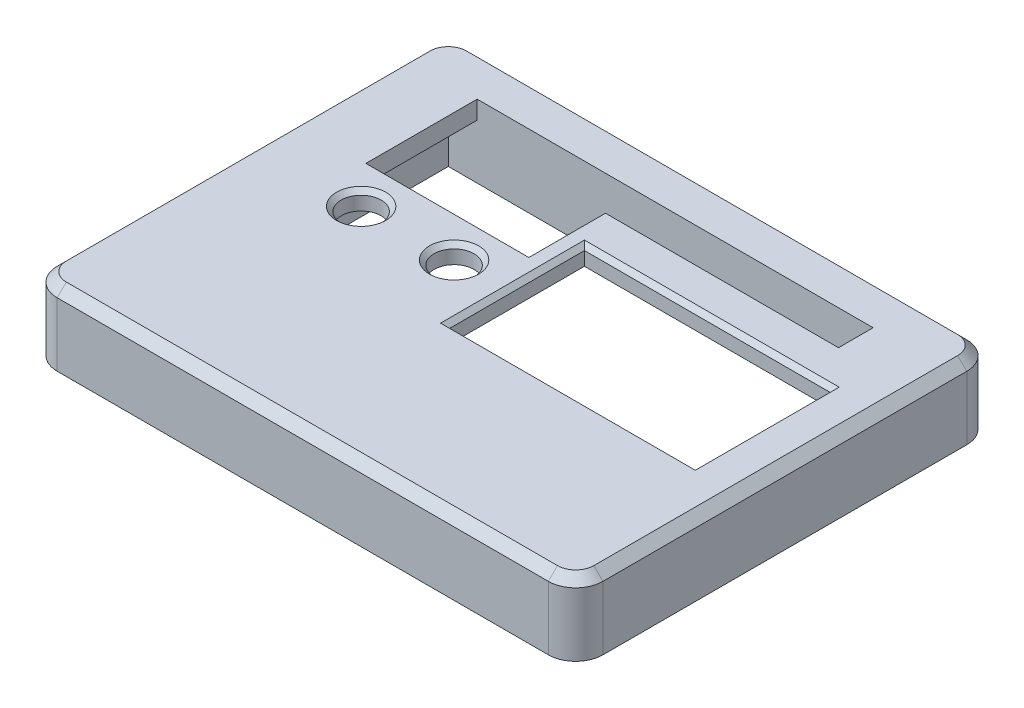
from build123d import *

# Parameters (mm, degrees)
SKETCH8_R           = 1.6
SKETCH8_W           = 27.014473095
SKETCH8_H           = 14.822230288
SKETCH8_R_2         = 2.2
BOSS_EXTRUDE4_DEPTH = 8
SKETCH13_R          = 1.6
BOSS_EXTRUDE5_DEPTH = 3
CHAMFER1_SIZE       = 1
CHAMFER2_SIZE       = 0.5
CHAMFER3_SIZE       = 0.5
SKETCH14_W          = 50
SKETCH14_H          = 36
CUT_EXTRUDE1_DEPTH  = 6
CUT_EXTRUDE2_DEPTH  = 26


with BuildPart() as part:
    # Sketch8 → Boss-Extrude4 (new body)
    with BuildSketch(Plane(origin=(0, 0, 0), x_dir=(1, 0, 0), z_dir=(0, 1, 0))):
        with BuildLine():
            Line((57.021874501, 46.194423092), (3.021874501, 46.194423092))
            ThreePointArc((3.021874501, 46.194423092), (0.900554158, 45.315743435), (0.021874501, 43.194423092))
            Line((0.021874501, 43.194423092), (0.021874501, 3.194423092))
            ThreePointArc((0.021874501, 3.194423092), (0.900554158, 1.073102748), (3.021874501, 0.194423092))
            Line((3.021874501, 0.194423092), (57.021874501, 0.194423092))
            ThreePointArc((57.021874501, 0.194423092), (59.143194845, 1.073102748), (60.021874501, 3.194423092))
            Line((60.021874501, 3.194423092), (60.021874501, 43.194423092))
            ThreePointArc((60.021874501, 43.194423092), (59.143194845, 45.315743435), (57.021874501, 46.194423092))
        make_face()
        with Locations((30.021874501, 2.694423092)):
            Circle(SKETCH8_R, mode=Mode.SUBTRACT)
        with Locations((2.521874501, 23.194423092)):
            Circle(SKETCH8_R, mode=Mode.SUBTRACT)
        with Locations((30.021874501, 43.694423092)):
            Circle(SKETCH8_R, mode=Mode.SUBTRACT)
        Polygon((8.193945871, 28.957965299), (8.193945871, 41.194423092), (51.724223397, 41.194423092), (51.724223397, 37.388033247), (26.110307843, 37.388033247), (26.110307843, 28.957965299), align=None, mode=Mode.SUBTRACT)
        with Locations((41.514637954, 25.761884129)):
            Rectangle(SKETCH8_W, SKETCH8_H, mode=Mode.SUBTRACT)
        with Locations((22.240201254, 24.607965299)):
            Circle(SKETCH8_R_2, mode=Mode.SUBTRACT)
        with Locations((12.021874501, 24.607965299)):
            Circle(SKETCH8_R_2, mode=Mode.SUBTRACT)
    extrude(amount=BOSS_EXTRUDE4_DEPTH)

    # Sketch13 → Boss-Extrude5 (add)
    with BuildSketch(Plane(origin=(0, 8, 0), x_dir=(1, 0, 0), z_dir=(0, 1, 0))):
        with Locations((2.521874501, 23.194423092)):
            Circle(SKETCH13_R)
        with Locations((30.021874501, 2.694423092)):
            Circle(SKETCH13_R)
        with Locations((30.021874501, 43.694423092)):
            Circle(SKETCH13_R)
    extrude(amount=-BOSS_EXTRUDE5_DEPTH)

    # Chamfer1
    chamfer1_edges = [part.edges().sort_by_distance(p)[0] for p in [
        (59.143194845, 8, -1.073102748),
        (60.021874501, 8, -23.194423092),
        (59.143194845, 8, -45.315743435),
        (30.021874501, 8, -46.194423092),
        (0.900554158, 8, -45.315743435),
        (0.021874501, 8, -23.194423092),
        (0.900554158, 8, -1.073102748),
        (30.021874501, 8, -0.194423092),
    ]]
    chamfer(chamfer1_edges, length=CHAMFER1_SIZE)

    # Chamfer2
    chamfer2_edges = [part.edges().sort_by_distance(p)[0] for p in [
        (41.514637954, 8, -33.172999273),
        (55.021874501, 8, -25.761884129),
        (41.514637954, 8, -18.350768985),
        (28.007401406, 8, -25.761884129),
    ]]
    chamfer(chamfer2_edges, length=CHAMFER2_SIZE)

    # Chamfer3
    chamfer3_edges = [part.edges().sort_by_distance(p)[0] for p in [
        (20.040201254, 8, -24.607965299),
        (9.821874501, 8, -24.607965299),
    ]]
    chamfer(chamfer3_edges, length=CHAMFER3_SIZE)

    # Sketch14 → Cut-Extrude1 (cut)
    with BuildSketch(Plane.XZ):
        with Locations((30.021874501, -23.194423092)):
            Rectangle(SKETCH14_W, SKETCH14_H)
    extrude(amount=-CUT_EXTRUDE1_DEPTH, mode=Mode.SUBTRACT)

    # Sketch15 → Cut-Extrude2 (cut)
    with BuildSketch(Plane.ZY.offset(-26.110307843)):
        Polygon((-37.388033247, 7), (-34.086693064, 6), (-37.388033247, 6), align=None)
    extrude(amount=-CUT_EXTRUDE2_DEPTH, mode=Mode.SUBTRACT)


solid = part.part
